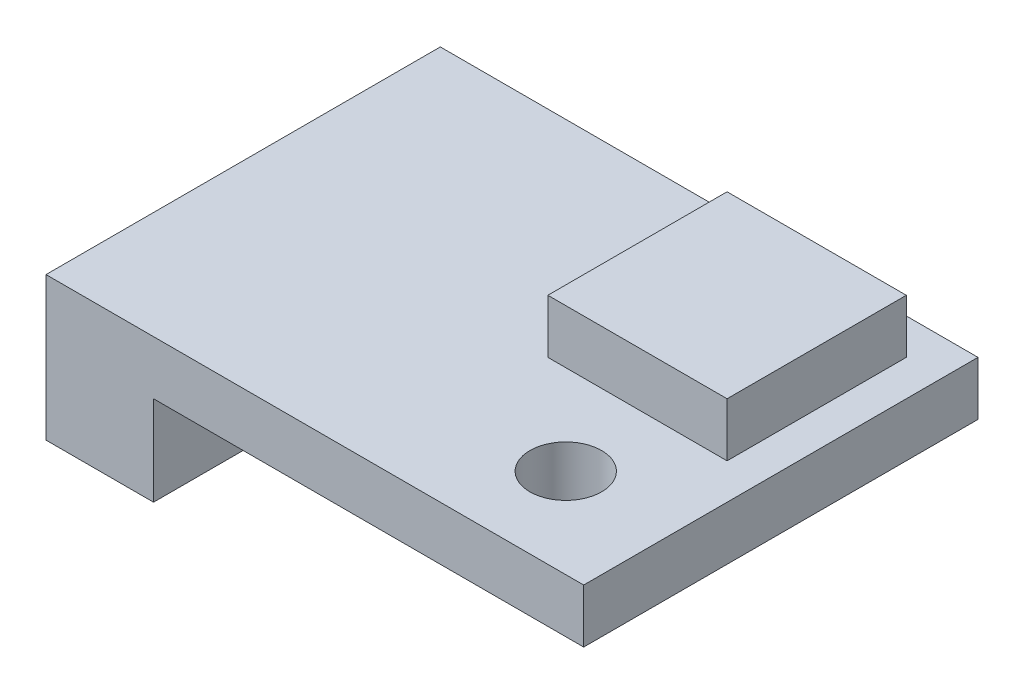
from build123d import *

# Parameters (mm, degrees)
SKETCH_1_R      = 1
SKETCH_1_W      = 5
SKETCH_1_H      = 5
SKETCH_1_W_2    = 3
SKETCH_1_H_2    = 11
EXTRUDE_1_DEPTH = 1.5
SKETCH_1_3_W    = 3
SKETCH_1_3_H    = 11
EXTRUDE_2_DEPTH = 2.5
EXTRUDE_START   = 1.5
SKETCH_1_4_W    = 5
SKETCH_1_4_H    = 5
EXTRUDE_3_DEPTH = 1.5


with BuildPart() as part:
    # Эскиз1 → Бобышка-Вытянуть1 (new body)
    with BuildSketch(Plane(origin=(0, 0, 0), x_dir=(1, 0, 0), z_dir=(0, 1, 0))):
        Polygon((7.5, -3), (7.5, 5.5), (-4.5, 5.5), (-4.5, -5.5), (4.5, -5.5), (7.5, -5.5), align=None)
        with Locations((4.5, -3)):
            Circle(SKETCH_1_R, mode=Mode.SUBTRACT)
        with Locations((4, 2)):
            Rectangle(SKETCH_1_W, SKETCH_1_H, mode=Mode.SUBTRACT)
        with Locations((-6, 0)):
            Rectangle(SKETCH_1_W_2, SKETCH_1_H_2)
        with Locations((4, 2)):
            Rectangle(SKETCH_1_W, SKETCH_1_H)
    extrude(amount=EXTRUDE_1_DEPTH)

    # Эскиз1<3> → Бобышка-Вытянуть2 (add)
    with BuildSketch(Plane(origin=(0, 0, 0), x_dir=(1, 0, 0), z_dir=(0, 1, 0))):
        with Locations((-6, 0)):
            Rectangle(SKETCH_1_3_W, SKETCH_1_3_H)
    extrude(amount=-EXTRUDE_2_DEPTH)

    # Эскиз1<4> → Бобышка-Вытянуть3 (add)
    with BuildSketch(Plane(origin=(0, 0, 0), x_dir=(1, 0, 0), z_dir=(0, 1, 0)).offset(EXTRUDE_START)):
        with Locations((4, 2)):
            Rectangle(SKETCH_1_4_W, SKETCH_1_4_H)
    extrude(amount=EXTRUDE_3_DEPTH)


solid = part.part
